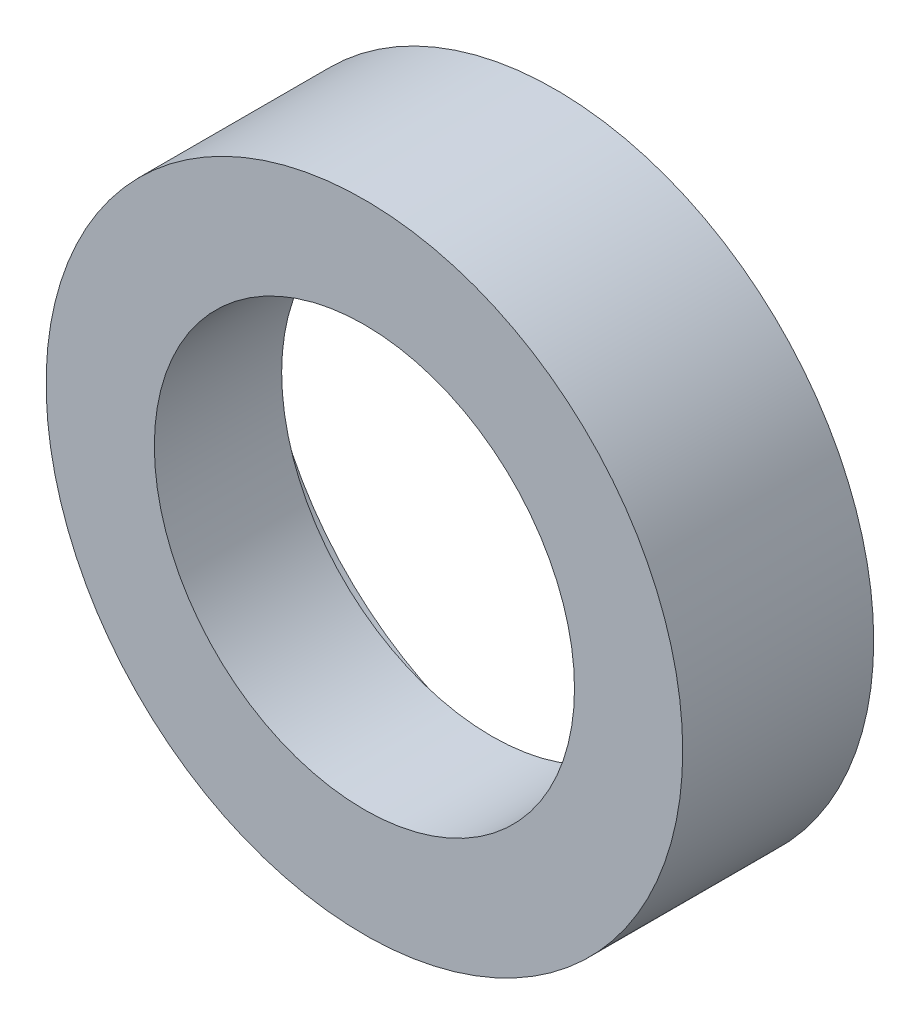
from build123d import *

# Parameters (mm, degrees)
SKETCH1_R           = 50
SKETCH1_R_2         = 46
BOSS_EXTRUDE1_DEPTH = 10
SKETCH2_R           = 50
SKETCH2_R_2         = 33
BOSS_EXTRUDE2_DEPTH = 20


with BuildPart() as part:
    # Sketch1 → Boss-Extrude1 (new body)
    with BuildSketch(Plane.XY):
        Circle(SKETCH1_R)
        Circle(SKETCH1_R_2, mode=Mode.SUBTRACT)
    extrude(amount=BOSS_EXTRUDE1_DEPTH)

    # Sketch2 → Boss-Extrude2 (add)
    with BuildSketch(Plane.XY.offset(10)):
        Circle(SKETCH2_R)
        Circle(SKETCH2_R_2, mode=Mode.SUBTRACT)
    extrude(amount=BOSS_EXTRUDE2_DEPTH)


solid = part.part
